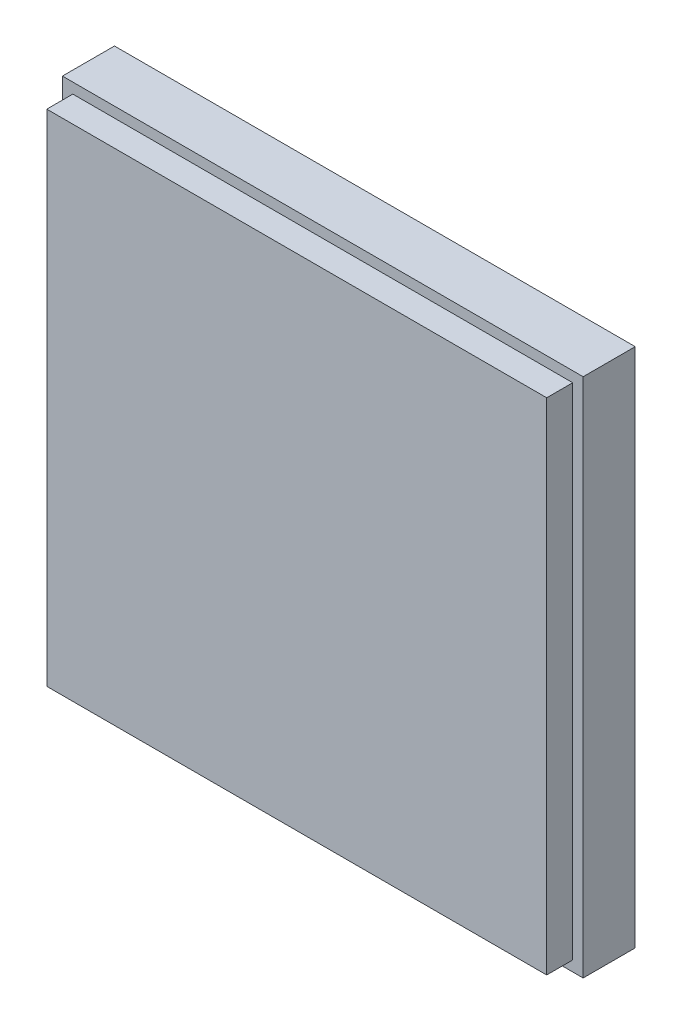
from build123d import *

# Parameters (mm, degrees)
SKETCH2_W           = 100
SKETCH2_H           = 100
BOSS_EXTRUDE1_DEPTH = 10
SKETCH3_W           = 96
SKETCH3_H           = 96
BOSS_EXTRUDE2_DEPTH = 5


with BuildPart() as part:
    # Sketch2 → Boss-Extrude1 (new body)
    with BuildSketch(Plane.XY):
        with Locations((-16.025505931, -31.476121393)):
            Rectangle(SKETCH2_W, SKETCH2_H)
    extrude(amount=BOSS_EXTRUDE1_DEPTH)

    # Sketch3 → Boss-Extrude2 (add)
    with BuildSketch(Plane.XY.offset(10)):
        with Locations((-16.025505931, -31.476121393)):
            Rectangle(SKETCH3_W, SKETCH3_H)
    extrude(amount=BOSS_EXTRUDE2_DEPTH)


solid = part.part
